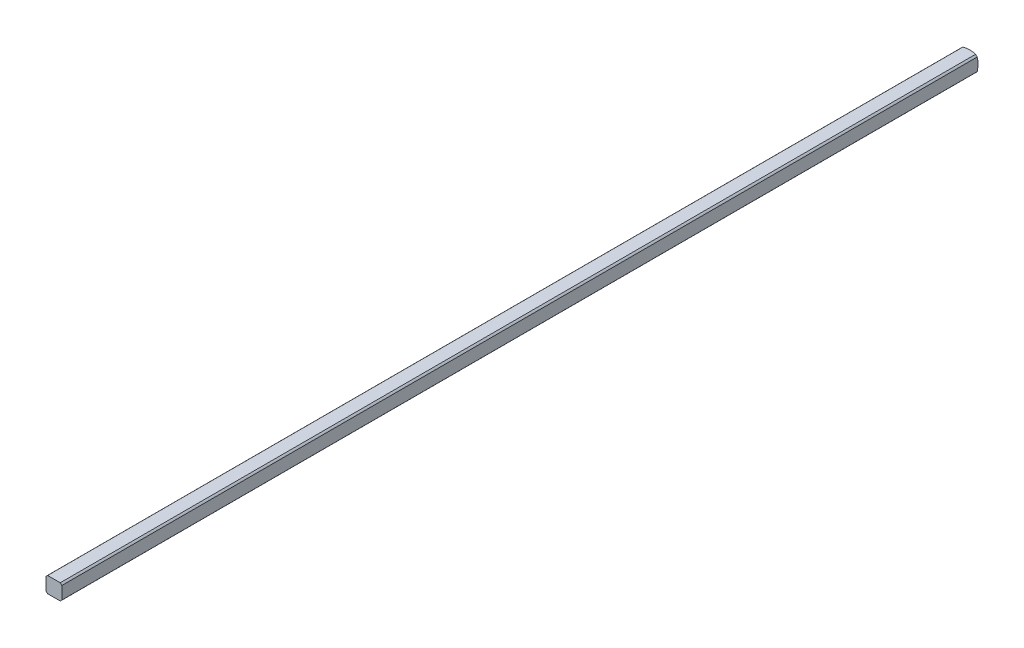
from build123d import *

# Parameters (mm, degrees)
SKETCH1_W           = 3.175
SKETCH1_H           = 3.175
BOSS_EXTRUDE1_DEPTH = 152.4
SKETCH2_OUTSIDE_W   = 35.668
SKETCH2_OUTSIDE_H   = 35.668
SKETCH2_OUTSIDE_R   = 2.032
CUT_EXTRUDE1_DEPTH  = 153.416535561
SKETCH4_W           = 120.65
SKETCH4_H           = 3.175
CUT_EXTRUDE2_DEPTH  = 305.820669872


with BuildPart() as part:
    # Sketch1 → Boss-Extrude1 (new body)
    with BuildSketch(Plane.XY):
        Rectangle(SKETCH1_W, SKETCH1_H)
    extrude(amount=BOSS_EXTRUDE1_DEPTH)

    # Sketch2 outside → Cut-Extrude1 (cut, through all)
    with BuildSketch(Plane(origin=(0, 0, 0), x_dir=(-1, 0, 0), z_dir=(0, 0, -1))):
        Rectangle(SKETCH2_OUTSIDE_W, SKETCH2_OUTSIDE_H)
        Circle(SKETCH2_OUTSIDE_R, mode=Mode.SUBTRACT)
    extrude(amount=-CUT_EXTRUDE1_DEPTH, mode=Mode.SUBTRACT)

    # Sketch3 → Cut-Revolve1 (revolve, cut)
    with BuildSketch(Plane(origin=(0, 0, 0), x_dir=(1, 0, 0), z_dir=(0, 1, 0))):
        with BuildLine():
            Line((-5.053685963, -4.40273269), (-5.053685963, 5.740530545))
            Line((-5.053685963, 5.740530545), (0, 5.740530545))
            Line((0, 5.740530545), (0, 0.160877736))
            ThreePointArc((0, 0.160877736), (-3.404639553, -1.148866368), (-5.053685963, -4.40273269))
        make_face()
    revolve(axis=Axis((0, 0, 152.4), (0, 0, -1)), mode=Mode.SUBTRACT)

    # Mirror1: part across plane


with BuildPart() as part_1:
    add(part.part)
    add(part.part.mirror(Plane(origin=(0, 0, 152.4), x_dir=(1, 0, 0), z_dir=(0, 0, -1))))

    # Sketch4 → Cut-Extrude2 (cut, through all)
    with BuildSketch(Plane(origin=(1.5875, 0, 0), x_dir=(0, 0, -1), z_dir=(1, 0, 0))):
        with Locations((-244.211774642, 0)):
            Rectangle(SKETCH4_W, SKETCH4_H)
    extrude(amount=-CUT_EXTRUDE2_DEPTH, mode=Mode.SUBTRACT)


with BuildPart() as body_2:
    # of the pieces the cut leaves, the one that is kept (cut_extrude2_keep)
    add(part_1.part.solids().sort_by_distance((1.268411507, -1.5875, 0.263225358))[0])


solid = body_2.part
